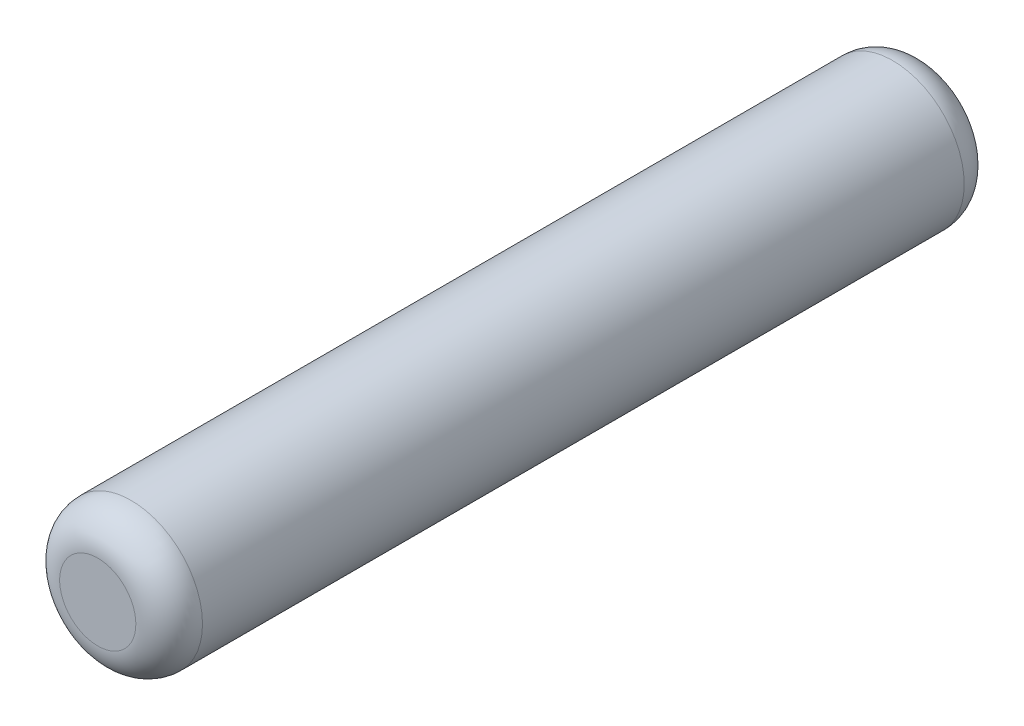
from build123d import *

# Parameters (mm, degrees)
SKETCH1_R           = 0.75
BOSS_EXTRUDE1_DEPTH = 4.35
FILLET1_R           = 0.35


with BuildPart() as part:
    # Sketch1 → Boss-Extrude1 (new body, symmetric)
    with BuildSketch(Plane.XY):
        Circle(SKETCH1_R)
    extrude(amount=BOSS_EXTRUDE1_DEPTH, both=True)

    # Fillet1
    fillet1_edges = [part.edges().sort_by_distance(p)[0] for p in [
        (-0.75, 0, -4.35),
        (-0.75, 0, 4.35),
    ]]
    fillet(fillet1_edges, radius=FILLET1_R)


solid = part.part
